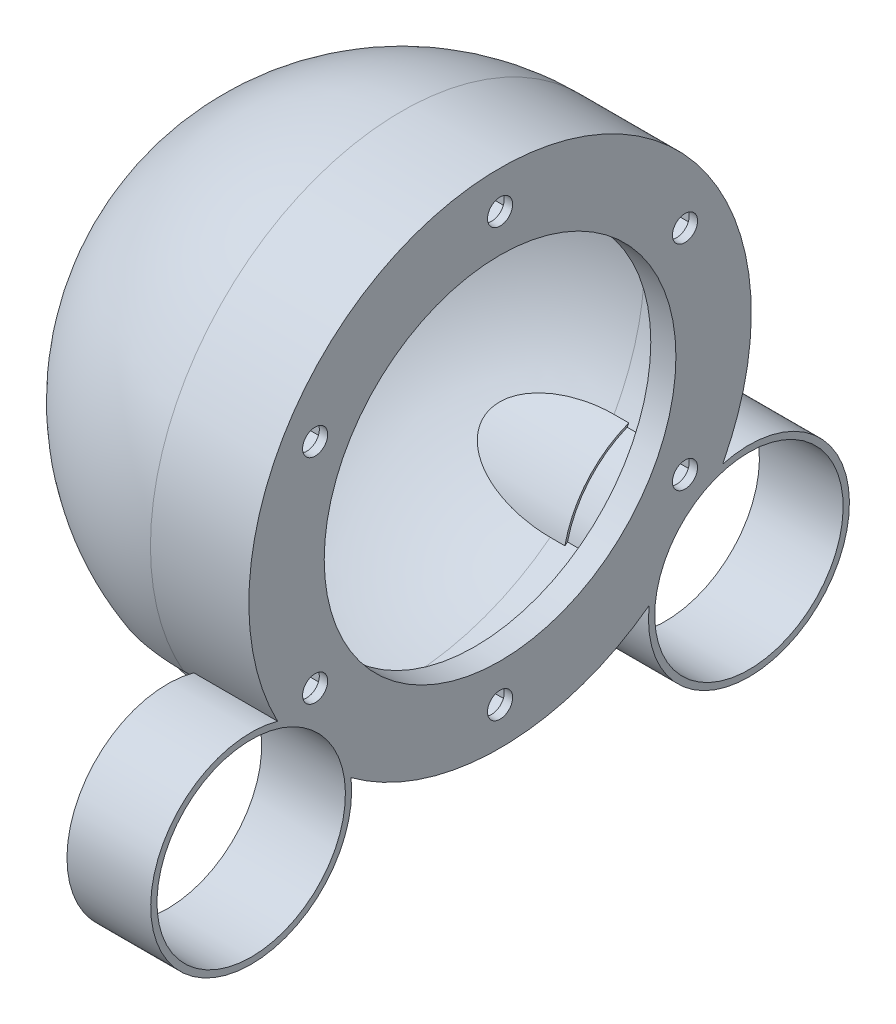
from build123d import *

# Parameters (mm, degrees)
REVOLUCI_N3_ANGLE       = 180
VACIADO1_T              = -2
CROQUIS5_R              = 60
CROQUIS5_R_2            = 58
SALIENTE_EXTRUIR1_DEPTH = 17.5
CROQUIS6_R              = 60
CROQUIS6_R_2            = 42
CROQUIS6_R_3            = 3
SALIENTE_EXTRUIR2_DEPTH = 6
CROQUIS7_R              = 24
CROQUIS7_R_2            = 22.5
SALIENTE_EXTRUIR3_DEPTH = 20
CROQUIS8_R              = 22.5
CORTAR_EXTRUIR2_DEPTH   = 20
CROQUIS9_R              = 22.5
CORTAR_EXTRUIR3_DEPTH   = 64.5
SALIENTE_EXTRUIR4_REACH = 65.5
CORTAR_EXTRUIR4_DEPTH   = 4


with BuildPart() as part:
    # Croquis4 → Revolución3 (revolve)
    with BuildSketch(Plane(origin=(0, 0, 0), x_dir=(0, 0, -1), z_dir=(1, 0, 0))):
        with BuildLine():
            Line((-60, 0), (60, 0))
            ThreePointArc((60, 0), (0, 60), (-60, 0))
        make_face()
    revolve(axis=Axis((0, 0, 60), (0, 0, 1)), revolution_arc=REVOLUCI_N3_ANGLE)

    # Vaciado1
    vaciado1_openings = [part.faces().sort_by_distance(p)[0] for p in [
        (0, 0, -60),
    ]]
    offset(amount=VACIADO1_T, openings=vaciado1_openings)

    # Croquis5 → Saliente-Extruir1 (add)
    with BuildSketch(Plane(origin=(0, 0, 0), x_dir=(0, 0, -1), z_dir=(1, 0, 0))):
        Circle(CROQUIS5_R)
        Circle(CROQUIS5_R_2, mode=Mode.SUBTRACT)
    extrude(amount=SALIENTE_EXTRUIR1_DEPTH)

    # Croquis6 → Saliente-Extruir2 (add)
    with BuildSketch(Plane(origin=(17.5, 0, 0), x_dir=(0, 0, -1), z_dir=(1, 0, 0))):
        Circle(CROQUIS6_R)
        Circle(CROQUIS6_R_2, mode=Mode.SUBTRACT)
        with Locations((0, 51)):
            Circle(CROQUIS6_R_3, mode=Mode.SUBTRACT)
        with Locations((44.167295593, 25.5)):
            Circle(CROQUIS6_R_3, mode=Mode.SUBTRACT)
        with Locations((44.167295593, -25.5)):
            Circle(CROQUIS6_R_3, mode=Mode.SUBTRACT)
        with Locations((0, -51)):
            Circle(CROQUIS6_R_3, mode=Mode.SUBTRACT)
        with Locations((-44.167295593, -25.5)):
            Circle(CROQUIS6_R_3, mode=Mode.SUBTRACT)
        with Locations((-44.167295593, 25.5)):
            Circle(CROQUIS6_R_3, mode=Mode.SUBTRACT)
    extrude(amount=SALIENTE_EXTRUIR2_DEPTH)

    # Croquis7 → Saliente-Extruir3 (add)
    with BuildSketch(Plane(origin=(23.5, 0, 0), x_dir=(0, 0, -1), z_dir=(1, 0, 0))):
        with Locations((59.439232835, -51)):
            Circle(CROQUIS7_R)
        with Locations((59.439232835, -51)):
            Circle(CROQUIS7_R_2, mode=Mode.SUBTRACT)
        with Locations((-59.439232835, -51)):
            Circle(CROQUIS7_R)
        with Locations((-59.439232835, -51)):
            Circle(CROQUIS7_R_2, mode=Mode.SUBTRACT)
    extrude(amount=-SALIENTE_EXTRUIR3_DEPTH)

    # Croquis8 → Cortar-Extruir2 (cut)
    with BuildSketch(Plane(origin=(23.5, 0, 0), x_dir=(0, 0, -1), z_dir=(1, 0, 0))):
        with Locations((-59.439232835, -51)):
            Circle(CROQUIS8_R)
        with Locations((59.439232835, -51)):
            Circle(CROQUIS8_R)
    extrude(amount=-CORTAR_EXTRUIR2_DEPTH, mode=Mode.SUBTRACT)

    # Croquis9 → Cortar-Extruir3 (cut, through all)
    with BuildSketch(Plane(origin=(3.5, 0, 0), x_dir=(0, 0, -1), z_dir=(1, 0, 0))):
        with Locations((-59.439232835, -51)):
            Circle(CROQUIS9_R)
        with Locations((59.439232835, -51)):
            Circle(CROQUIS9_R)
    extrude(amount=-CORTAR_EXTRUIR3_DEPTH, mode=Mode.SUBTRACT)

    # Croquis10 → Saliente-Extruir4 (add, up to next)
    with BuildSketch(Plane(origin=(3.5, 0, 0), x_dir=(0, 0, -1), z_dir=(1, 0, 0)), mode=Mode.PRIVATE) as saliente_extruir4_sk1:
        with BuildLine():
            ThreePointArc((-37.297899218, -46.998582041), (-42.363355169, -36.348569969), (-52.120051429, -29.723731917))
            ThreePointArc((-52.120051429, -29.723731917), (-52.804439439, -28.490194375), (-53.459638302, -27.240908072))
            ThreePointArc((-53.459638302, -27.240908072), (-40.845499377, -35.046220633), (-35.047443828, -48.699863256))
            ThreePointArc((-35.047443828, -48.699863256), (-36.182672021, -47.86245131), (-37.297899218, -46.998582041))
        make_face()
    saliente_extruir4_tool1 = extrude(saliente_extruir4_sk1.sketch, amount=-SALIENTE_EXTRUIR4_REACH, mode=Mode.PRIVATE) - part.part
    add(saliente_extruir4_tool1.solids().sort_by_distance((3.5, -28.355933, 52.555595))[0])
    # Croquis10 → Saliente-Extruir4 (add, up to next)
    with BuildSketch(Plane(origin=(3.5, 0, 0), x_dir=(0, 0, -1), z_dir=(1, 0, 0)), mode=Mode.PRIVATE) as saliente_extruir4_sk2:
        with BuildLine():
            ThreePointArc((37.297899218, -46.998582041), (36.182672021, -47.86245131), (35.047443828, -48.699863256))
            ThreePointArc((35.047443828, -48.699863256), (40.845499377, -35.046220633), (53.459638302, -27.240908072))
            ThreePointArc((53.459638302, -27.240908072), (52.804439439, -28.490194375), (52.120051429, -29.723731917))
            ThreePointArc((52.120051429, -29.723731917), (42.363355169, -36.348569969), (37.297899218, -46.998582041))
        make_face()
    saliente_extruir4_tool2 = extrude(saliente_extruir4_sk2.sketch, amount=-SALIENTE_EXTRUIR4_REACH, mode=Mode.PRIVATE) - part.part
    add(saliente_extruir4_tool2.solids().sort_by_distance((3.5, -36.164448, -42.148766))[0])

    # Croquis11 → Cortar-Extruir4 (cut)
    with BuildSketch(Plane.ZY.offset(-17.5)):
        Polygon((48.167295593, 27.809401077), (44.167295593, 30.118802154), (40.167295593, 27.809401077), (40.167295593, 23.190598923), (44.167295593, 20.881197846), (48.167295593, 23.190598923), align=None)
        Polygon((0, 55.618802154), (-4, 53.309401077), (-4, 48.690598923), (0, 46.381197846), (4, 48.690598923), (4, 53.309401077), align=None)
        Polygon((48.167295593, -27.809401077), (48.167295593, -23.190598923), (44.167295593, -20.881197846), (40.167295593, -23.190598923), (40.167295593, -27.809401077), (44.167295593, -30.118802154), align=None)
        Polygon((0, -55.618802154), (4, -53.309401077), (4, -48.690598923), (0, -46.381197846), (-4, -48.690598923), (-4, -53.309401077), align=None)
        Polygon((-48.167295593, -27.809401077), (-44.167295593, -30.118802154), (-40.167295593, -27.809401077), (-40.167295593, -23.190598923), (-44.167295593, -20.881197846), (-48.167295593, -23.190598923), align=None)
        Polygon((-48.167295593, 27.809401077), (-48.167295593, 23.190598923), (-44.167295593, 20.881197846), (-40.167295593, 23.190598923), (-40.167295593, 27.809401077), (-44.167295593, 30.118802154), align=None)
    extrude(amount=-CORTAR_EXTRUIR4_DEPTH, mode=Mode.SUBTRACT)


solid = part.part
